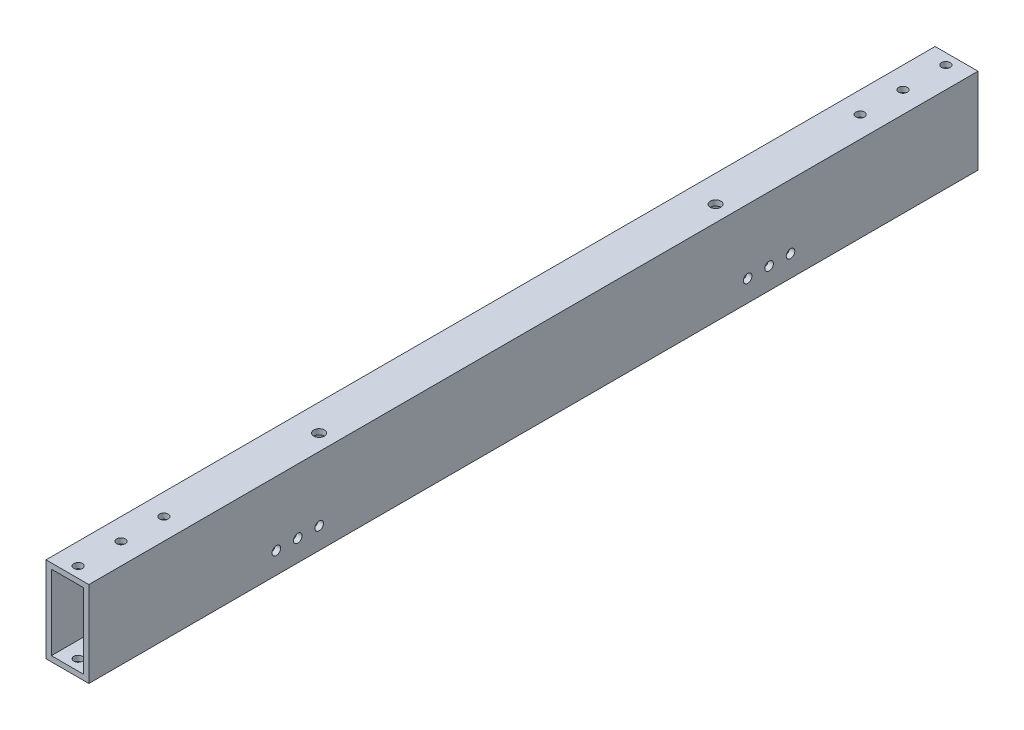
from build123d import *

# Parameters (mm, degrees)
SKETCH1_W                                       = 25.4
SKETCH1_H                                       = 50.8
SKETCH1_W_2                                     = 19.05
SKETCH1_H_2                                     = 44.45
EXTRUDE_THIN1_DEPTH                             = 527.05
F_10_CLEARANCE_HOLE1_D                          = 5.1054
F_1_8_0_13_DIAMETER_HOLE1_D                     = 3.302
F_1_8_0_13_DIAMETER_HOLE1_DEPTH                 = 3.175
F_1_4_0_25_DIAMETER_HOLE1_D                     = 6.35
F_1_4_0_25_DIAMETER_HOLE1_DEPTH                 = 10.7188
F_1_4_0_25_DIAMETER_HOLE1_TIP                   = 1.907732465
CBORE_FOR_10_SOCKET_HEAD_CAP_SCREW1_D           = 5.1054
CBORE_FOR_10_SOCKET_HEAD_CAP_SCREW1_CBORE_D     = 9.525
CBORE_FOR_10_SOCKET_HEAD_CAP_SCREW1_CBORE_DEPTH = 8.001


with BuildPart() as part:
    # Sketch1 → Extrude-Thin1 (new body)
    with BuildSketch(Plane.XY):
        Rectangle(SKETCH1_W, SKETCH1_H)
        Rectangle(SKETCH1_W_2, SKETCH1_H_2, mode=Mode.SUBTRACT)
    extrude(amount=EXTRUDE_THIN1_DEPTH)

    # #10 Clearance Hole1 (through all)
    with Locations(Plane(origin=(0, 25.4, 0), x_dir=(1, 0, 0), z_dir=(0, 1, 0))):
        with Locations((0, -520.7), (0, -495.3), (0, -469.9), (0, -6.35), (0, -31.75), (0, -57.15)):
            Hole(F_10_CLEARANCE_HOLE1_D / 2)

    # 1/8 (0.13) Diameter Hole1
    with Locations(Plane(origin=(0, -25.4, 0), x_dir=(-1, 0, 0), z_dir=(0, -1, 0))):
        with Locations((3.175, -70.358), (-3.175, -95.758), (3.175, -121.158), (-3.175, -146.558), (3.175, -171.958), (-3.175, -197.358), (-3.175, -248.158), (3.175, -273.558), (-3.175, -298.958), (3.175, -324.358), (-3.175, -349.758), (3.175, -375.158), (-3.175, -400.558), (3.175, -425.958), (-3.175, -451.358), (3.175, -222.758)):
            Hole(F_1_8_0_13_DIAMETER_HOLE1_D / 2, depth=F_1_8_0_13_DIAMETER_HOLE1_DEPTH)

    # 1/4 (0.25) Diameter Hole1
    with Locations(Plane(origin=(0, 25.4, 0), x_dir=(1, 0, 0), z_dir=(0, 1, 0))):
        with Locations((3.175, -146.05), (3.175, -381)):
            Hole(F_1_4_0_25_DIAMETER_HOLE1_D / 2, depth=F_1_4_0_25_DIAMETER_HOLE1_DEPTH)
            with Locations((0, 0, -(F_1_4_0_25_DIAMETER_HOLE1_DEPTH + F_1_4_0_25_DIAMETER_HOLE1_TIP / 2))):  # 118° drill point
                Cone(0, F_1_4_0_25_DIAMETER_HOLE1_D / 2, F_1_4_0_25_DIAMETER_HOLE1_TIP, mode=Mode.SUBTRACT)

    # CBORE for #10 Socket Head Cap Screw1 (through all)
    with Locations(Plane.ZY.offset(12.7)):
        with Locations((111.125, -12.7), (123.825, -12.7), (136.525, -12.7), (390.525, -12.7), (403.225, -12.7), (415.925, -12.7)):
            CounterBoreHole(CBORE_FOR_10_SOCKET_HEAD_CAP_SCREW1_D / 2, CBORE_FOR_10_SOCKET_HEAD_CAP_SCREW1_CBORE_D / 2, CBORE_FOR_10_SOCKET_HEAD_CAP_SCREW1_CBORE_DEPTH)


solid = part.part
